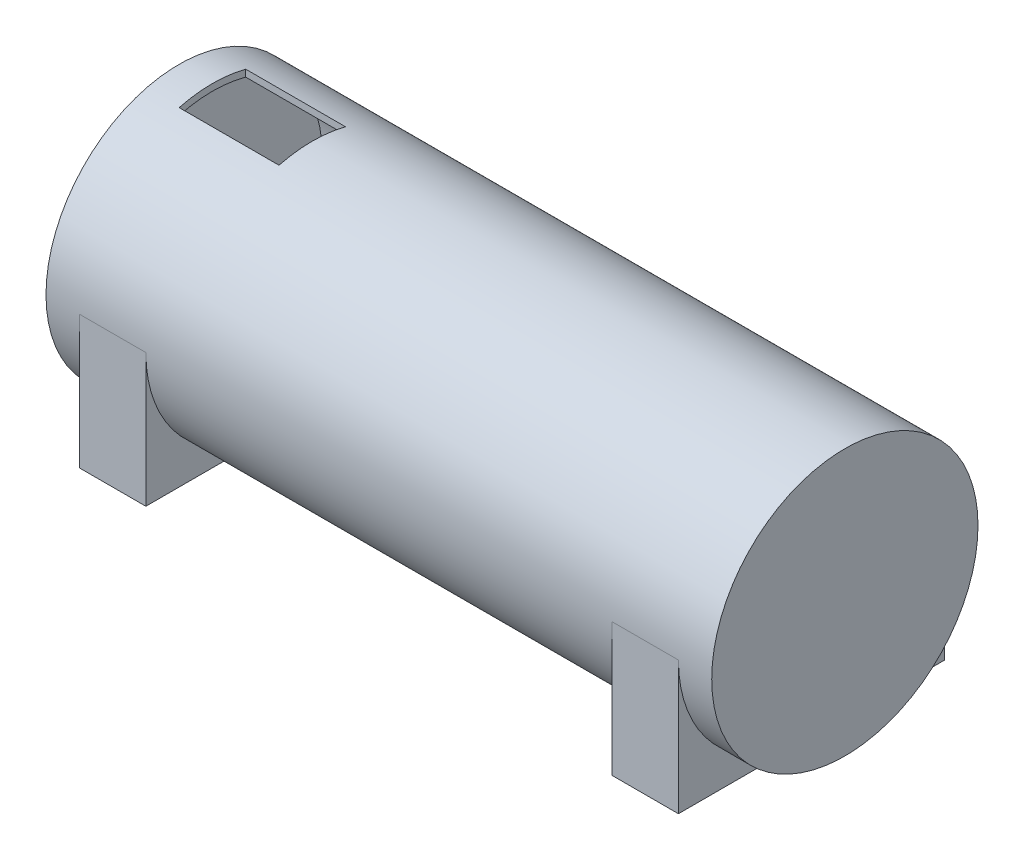
from build123d import *

# Parameters (mm, degrees)
IZIM1_W                     = 200
IZIM1_H                     = 40
IZIM2_R                     = 38
KES_EKSTR_ZYON2_DEPTH       = 190
IZIM3_W                     = 30
IZIM3_H                     = 20
KES_EKSTR_ZYON3_DEPTH       = 10
Y_KSEKLIK_EKSTR_ZYON1_DEPTH = 10
AYNALAMA2_COPY_1_DEPTH      = 10


with BuildPart() as part:
    # Çizim1 → Döndür1 (revolve)
    with BuildSketch(Plane.XY):
        with Locations((0, 20)):
            Rectangle(IZIM1_W, IZIM1_H)
    revolve(axis=Axis((100, 0, 0), (-1, 0, 0)))

    # Çizim2 → Kes-Ekstrüzyon2 (cut)
    with BuildSketch(Plane(origin=(-95, 0, 0), x_dir=(0, 0, -1), z_dir=(1, 0, 0))):
        Circle(IZIM2_R)
    extrude(amount=KES_EKSTR_ZYON2_DEPTH, mode=Mode.SUBTRACT)

    # Çizim3 → Kes-Ekstrüzyon3 (cut)
    with BuildSketch(Plane(origin=(0, 40, 0), x_dir=(1, 0, 0), z_dir=(0, 1, 0))):
        with Locations((-75, 0)):
            Rectangle(IZIM3_W, IZIM3_H)
    extrude(amount=-KES_EKSTR_ZYON3_DEPTH, mode=Mode.SUBTRACT)

    # Çizim5 → Yükseklik-Ekstrüzyon1 (add, symmetric)
    with BuildSketch(Plane(origin=(80, 0, 0), x_dir=(0, 0, -1), z_dir=(1, 0, 0))):
        with BuildLine():
            ThreePointArc((0, -40), (-28.284271247, -28.284271247), (-40, 0))
            Line((-40, 0), (-40, -40))
            Line((-40, -40), (0, -40))
        make_face()
    y_kseklik_ekstr_zyon1 = extrude(amount=Y_KSEKLIK_EKSTR_ZYON1_DEPTH, both=True)

    # Aynalama1: Yükseklik-Ekstrüzyon1 across plane
    add(y_kseklik_ekstr_zyon1.mirror(Plane.XY))

    # Aynalama2: Yükseklik-Ekstrüzyon1 across plane
    add(y_kseklik_ekstr_zyon1.mirror(Plane(origin=(0, 0, 0), x_dir=(0, 0, 1), z_dir=(1, 0, 0))))

    # Aynalama2 copy 1 sketch → Aynalama2 copy 1 (add, symmetric)
    with BuildSketch(Plane.ZY.offset(80)):
        with BuildLine():
            ThreePointArc((0, -40), (-28.284271247, -28.284271247), (-40, 0))
            Line((-40, 0), (-40, -40))
            Line((-40, -40), (0, -40))
        make_face()
    extrude(amount=AYNALAMA2_COPY_1_DEPTH, both=True)


solid = part.part
